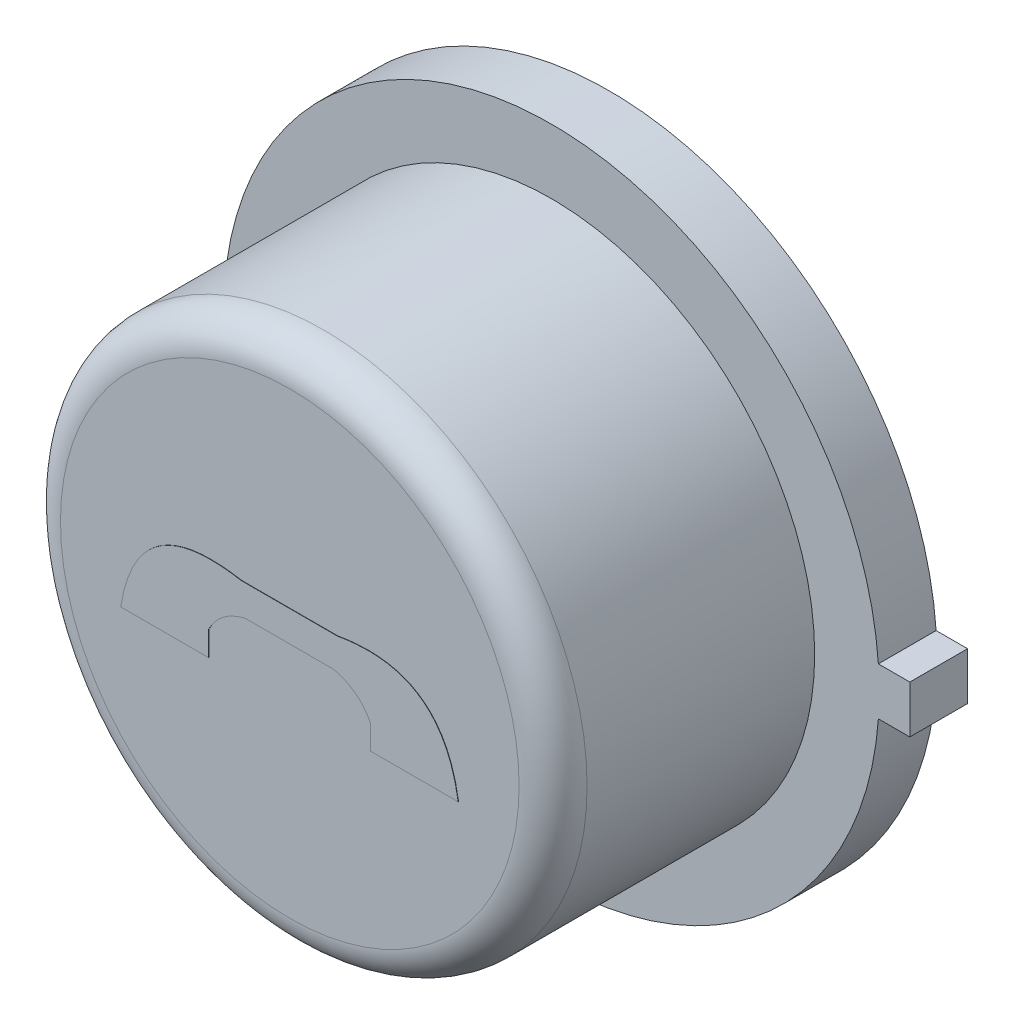
from build123d import *

# Parameters (mm, degrees)
BOSS_EXTRUDE1_DEPTH = 0.4318
SKETCH2_R           = 1.9685
BOSS_EXTRUDE2_DEPTH = 1.9558
SKETCH3_R           = 1.757566481
BOSS_EXTRUDE3_DEPTH = 0.00254
FILLET1_R           = 0.254
BOSS_EXTRUDE6_DEPTH = 0.00254


with BuildPart() as part:
    # Sketch1 → Boss-Extrude1 (new body)
    with BuildSketch(Plane.XY):
        with BuildLine():
            Line((2.6797, 0.1778), (2.4511, 0.1778))
            Line((2.4511, 0.1778), (2.44464279, 0.1778))
            ThreePointArc((2.44464279, 0.1778), (-2.4511, 0), (2.44464279, -0.1778))
            Line((2.44464279, -0.1778), (2.4511, -0.1778))
            Line((2.4511, -0.1778), (2.6797, -0.1778))
            Line((2.6797, -0.1778), (2.6797, 0.1778))
        make_face()
    extrude(amount=BOSS_EXTRUDE1_DEPTH)

    # Sketch2 → Boss-Extrude2 (add)
    with BuildSketch(Plane.XY.offset(0.4318)):
        Circle(SKETCH2_R)
    extrude(amount=BOSS_EXTRUDE2_DEPTH)

    # Sketch3 → Boss-Extrude3 (add)
    with BuildSketch(Plane(origin=(0, 0, 0), x_dir=(-1, 0, 0), z_dir=(0, 0, -1))):
        Circle(SKETCH3_R)
    extrude(amount=BOSS_EXTRUDE3_DEPTH)

    # Fillet1
    fillet1_edges = [part.edges().sort_by_distance(p)[0] for p in [
        (-1.9685, 0, 2.3876),
    ]]
    fillet(fillet1_edges, radius=FILLET1_R)

    # Sketch4 → Boss-Extrude6 (add)
    with BuildSketch(Plane.XY.offset(2.3876)):
        with BuildLine():
            add(Edge.make_bspline(
                [(-1.261686098, -0.327272856), (-1.14250793, 0.434027968), (-0.359856965, 0.293914961)],
                knots=[0, 0, 0, 1, 1, 1], degree=2))
            Line((-1.261686098, -0.327272856), (-0.605919476, -0.327272856))
            Line((-0.605919476, -0.327272856), (-0.605919476, -0.145694879))
            add(Edge.make_bspline(
                [(-0.605919476, -0.145694879), (-0.520411043, 0.020884548), (-0.328774143, 0.064553305)],
                knots=[0, 0, 0, 1, 1, 1], degree=2))
            Line((-0.328774143, 0.064553305), (0.328774143, 0.064553305))
            add(Edge.make_bspline(
                [(0.605919476, -0.145694879), (0.520411043, 0.020884548), (0.328774143, 0.064553305)],
                knots=[0, 0, 0, 1, 1, 1], degree=2))
            Line((0.605919476, -0.145694879), (0.605919476, -0.327272856))
            Line((0.605919476, -0.327272856), (1.261686098, -0.327272856))
            add(Edge.make_bspline(
                [(1.261686098, -0.327272856), (1.14250793, 0.434027968), (0.359856965, 0.293914961)],
                knots=[0, 0, 0, 1, 1, 1], degree=2))
            Line((0.359856965, 0.293914961), (-0.359856965, 0.293914961))
        make_face()
    extrude(amount=BOSS_EXTRUDE6_DEPTH)


solid = part.part
